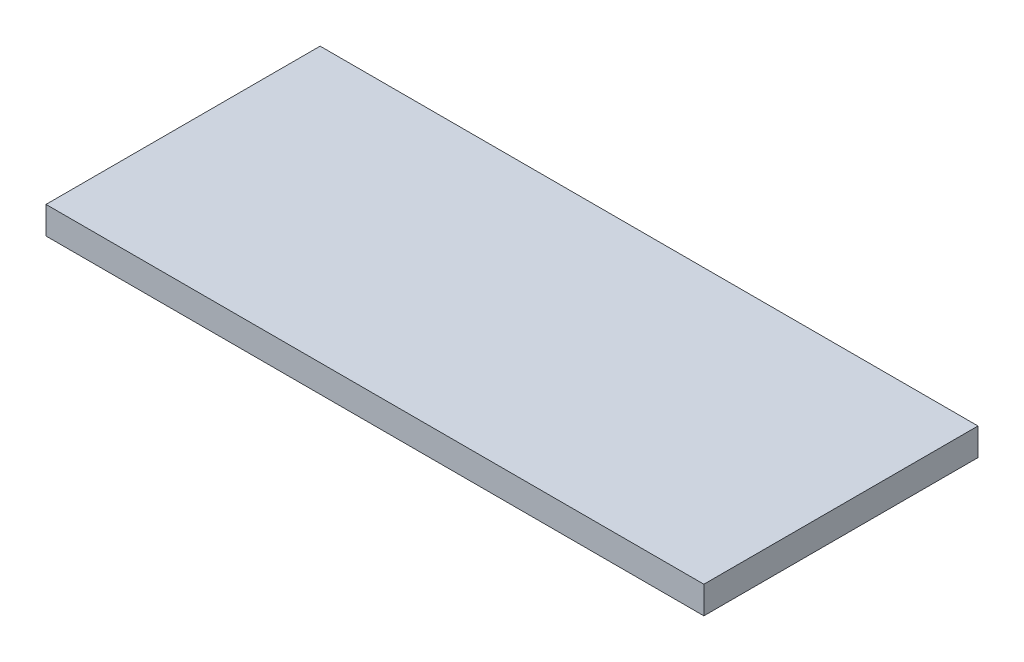
from build123d import *

# Parameters (mm, degrees)
CROQUIS1_W              = 152.4
CROQUIS1_H              = 63.5
SALIENTE_EXTRUIR1_DEPTH = 6.35


with BuildPart() as part:
    # Croquis1 → Saliente-Extruir1 (new body)
    with BuildSketch(Plane(origin=(0, 0, 0), x_dir=(1, 0, 0), z_dir=(0, 1, 0))):
        Rectangle(CROQUIS1_W, CROQUIS1_H)
    extrude(amount=SALIENTE_EXTRUIR1_DEPTH)


solid = part.part
